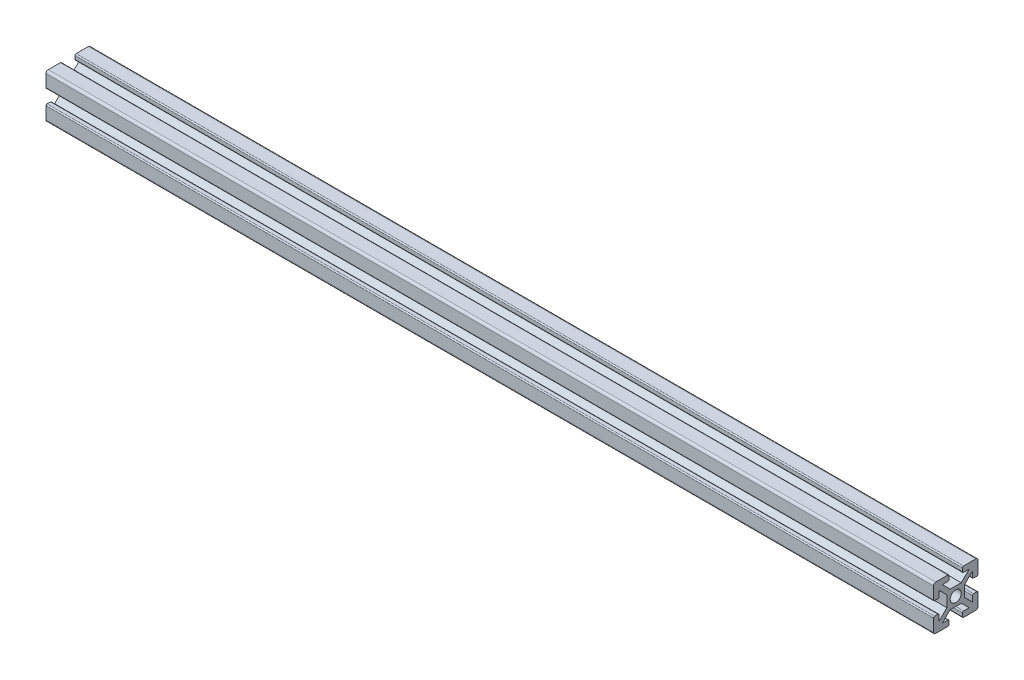
from build123d import *

# Parameters (mm, degrees)
SKETCH11_R                            = 2.5
ALUMINIUM_PROF_ALUMINIUM_PROF_1_DEPTH = 400
SKETCH12_R                            = 2.5
CUT_EXTRUDE1_DEPTH                    = 10


with BuildPart() as part:
    # Sketch11 → Aluminium prof ALUMINIUM PROF(1) (new body)
    with BuildSketch(Plane.YZ.offset(-188.350798937)):
        with BuildLine():
            Line((-2.5, 4), (2.5, 4))
            Line((2.5, 4), (6.035533906, 7.535533906))
            Line((6.035533906, 7.535533906), (3.535533906, 7.535533906))
            ThreePointArc((3.535533906, 7.535533906), (3.181980515, 7.681980515), (3.035533906, 8.035533906))
            Line((3.035533906, 8.035533906), (3.035533906, 9.535533906))
            ThreePointArc((3.035533906, 9.535533906), (3.181980515, 9.889087297), (3.535533906, 10.035533906))
            Line((3.535533906, 10.035533906), (9.035533906, 10.035533906))
            ThreePointArc((9.035533906, 10.035533906), (9.742640687, 9.742640687), (10.035533906, 9.035533906))
            Line((10.035533906, 9.035533906), (10.035533906, 3.535533906))
            ThreePointArc((10.035533906, 3.535533906), (9.889087297, 3.181980515), (9.535533906, 3.035533906))
            Line((9.535533906, 3.035533906), (8.035533906, 3.035533906))
            ThreePointArc((8.035533906, 3.035533906), (7.681980515, 3.181980515), (7.535533906, 3.535533906))
            Line((7.535533906, 3.535533906), (7.535533906, 6.035533906))
            Line((7.535533906, 6.035533906), (4, 2.5))
            Line((4, 2.5), (4, -2.5))
            Line((4, -2.5), (7.535533906, -6.035533906))
            Line((7.535533906, -6.035533906), (7.535533906, -3.535533906))
            ThreePointArc((7.535533906, -3.535533906), (7.681980515, -3.181980515), (8.035533906, -3.035533906))
            Line((8.035533906, -3.035533906), (9.535533906, -3.035533906))
            ThreePointArc((9.535533906, -3.035533906), (9.889087297, -3.181980515), (10.035533906, -3.535533906))
            Line((10.035533906, -3.535533906), (10.035533906, -9.035533906))
            ThreePointArc((10.035533906, -9.035533906), (9.742640687, -9.742640687), (9.035533906, -10.035533906))
            Line((9.035533906, -10.035533906), (3.535533906, -10.035533906))
            ThreePointArc((3.535533906, -10.035533906), (3.181980515, -9.889087297), (3.035533906, -9.535533906))
            Line((3.035533906, -9.535533906), (3.035533906, -8.035533906))
            ThreePointArc((3.035533906, -8.035533906), (3.181980515, -7.681980515), (3.535533906, -7.535533906))
            Line((3.535533906, -7.535533906), (6.035533906, -7.535533906))
            Line((6.035533906, -7.535533906), (2.5, -4))
            Line((2.5, -4), (-2.5, -4))
            Line((-2.5, -4), (-6.035533906, -7.535533906))
            Line((-6.035533906, -7.535533906), (-3.535533906, -7.535533906))
            ThreePointArc((-3.535533906, -7.535533906), (-3.181980515, -7.681980515), (-3.035533906, -8.035533906))
            Line((-3.035533906, -8.035533906), (-3.035533906, -9.535533906))
            ThreePointArc((-3.035533906, -9.535533906), (-3.181980515, -9.889087297), (-3.535533906, -10.035533906))
            Line((-3.535533906, -10.035533906), (-9.035533906, -10.035533906))
            ThreePointArc((-9.035533906, -10.035533906), (-9.742640687, -9.742640687), (-10.035533906, -9.035533906))
            Line((-10.035533906, -9.035533906), (-10.035533906, -3.535533906))
            ThreePointArc((-10.035533906, -3.535533906), (-9.889087297, -3.181980515), (-9.535533906, -3.035533906))
            Line((-9.535533906, -3.035533906), (-8.035533906, -3.035533906))
            ThreePointArc((-8.035533906, -3.035533906), (-7.681980515, -3.181980515), (-7.535533906, -3.535533906))
            Line((-7.535533906, -3.535533906), (-7.535533906, -6.035533906))
            Line((-7.535533906, -6.035533906), (-4, -2.5))
            Line((-4, -2.5), (-4, 2.5))
            Line((-4, 2.5), (-7.535533906, 6.035533906))
            Line((-7.535533906, 6.035533906), (-7.535533906, 3.535533906))
            ThreePointArc((-7.535533906, 3.535533906), (-7.681980515, 3.181980515), (-8.035533906, 3.035533906))
            Line((-8.035533906, 3.035533906), (-9.535533906, 3.035533906))
            ThreePointArc((-9.535533906, 3.035533906), (-9.889087297, 3.181980515), (-10.035533906, 3.535533906))
            Line((-10.035533906, 3.535533906), (-10.035533906, 9.035533906))
            ThreePointArc((-10.035533906, 9.035533906), (-9.742640687, 9.742640687), (-9.035533906, 10.035533906))
            Line((-9.035533906, 10.035533906), (-3.535533906, 10.035533906))
            ThreePointArc((-3.535533906, 10.035533906), (-3.181980515, 9.889087297), (-3.035533906, 9.535533906))
            Line((-3.035533906, 9.535533906), (-3.035533906, 8.035533906))
            ThreePointArc((-3.035533906, 8.035533906), (-3.181980515, 7.681980515), (-3.535533906, 7.535533906))
            Line((-3.535533906, 7.535533906), (-6.035533906, 7.535533906))
            Line((-6.035533906, 7.535533906), (-2.5, 4))
        make_face()
        Circle(SKETCH11_R, mode=Mode.SUBTRACT)
    extrude(amount=ALUMINIUM_PROF_ALUMINIUM_PROF_1_DEPTH)

    # Sketch12 → Cut-Extrude1 (cut)
    with BuildSketch(Plane(origin=(0, 0, -4), x_dir=(-1, 0, 0), z_dir=(0, 0, -1))):
        with Locations(Location((-201.649201063, 0, 0), (0, 0, 90))):
            Circle(SKETCH12_R)
    extrude(amount=-CUT_EXTRUDE1_DEPTH, mode=Mode.SUBTRACT)


solid = part.part
